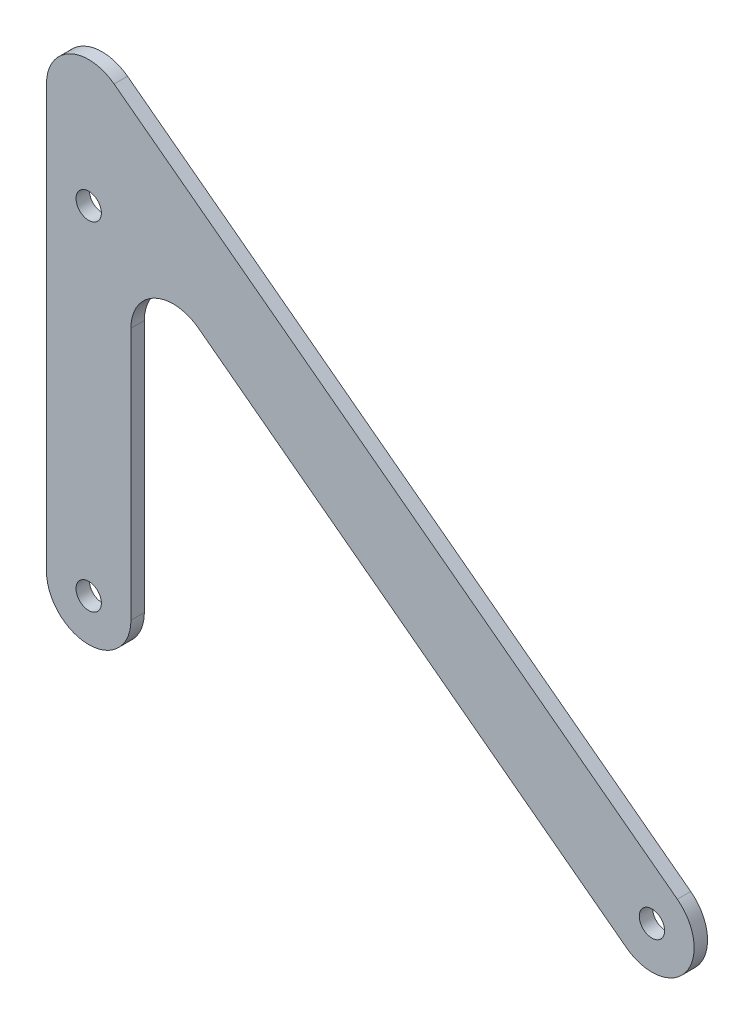
from build123d import *

# Parameters (mm, degrees)
SKETCH1_R           = 3
BOSS_EXTRUDE1_DEPTH = 3.175
FILLET1_R           = 10
SKETCH2_R           = 3
CUT_EXTRUDE1_DEPTH  = 4.175


with BuildPart() as part:
    # Sketch1 → Boss-Extrude1 (new body)
    with BuildSketch(Plane.XY):
        with BuildLine():
            Line((10, 0), (10, 79.943102917))
            Line((10, 79.943102917), (127.353979946, -8.489463967))
            ThreePointArc((127.353979946, -8.489463967), (141.358485278, -6.521259098), (139.390280409, 7.483246234))
            Line((139.390280409, 7.483246234), (-10, 120.056897083))
            Line((-10, 120.056897083), (-10, 0))
            ThreePointArc((-10, 0), (0, -10), (10, 0))
        make_face()
        Circle(SKETCH1_R, mode=Mode.SUBTRACT)
        with Locations((133.372130178, -0.503108866)):
            Circle(SKETCH1_R, mode=Mode.SUBTRACT)
    extrude(amount=BOSS_EXTRUDE1_DEPTH)

    # Fillet1
    fillet1_edges = [part.edges().sort_by_distance(p)[0] for p in [
        (-10, 120.056897083, 1.5875),
        (10, 79.943102917, 1.5875),
    ]]
    fillet(fillet1_edges, radius=FILLET1_R)

    # Sketch2 → Cut-Extrude1 (cut, through all)
    with BuildSketch(Plane.XY.offset(3.175)):
        with Locations((0, 80)):
            Circle(SKETCH2_R)
    extrude(amount=-CUT_EXTRUDE1_DEPTH, mode=Mode.SUBTRACT)


solid = part.part
